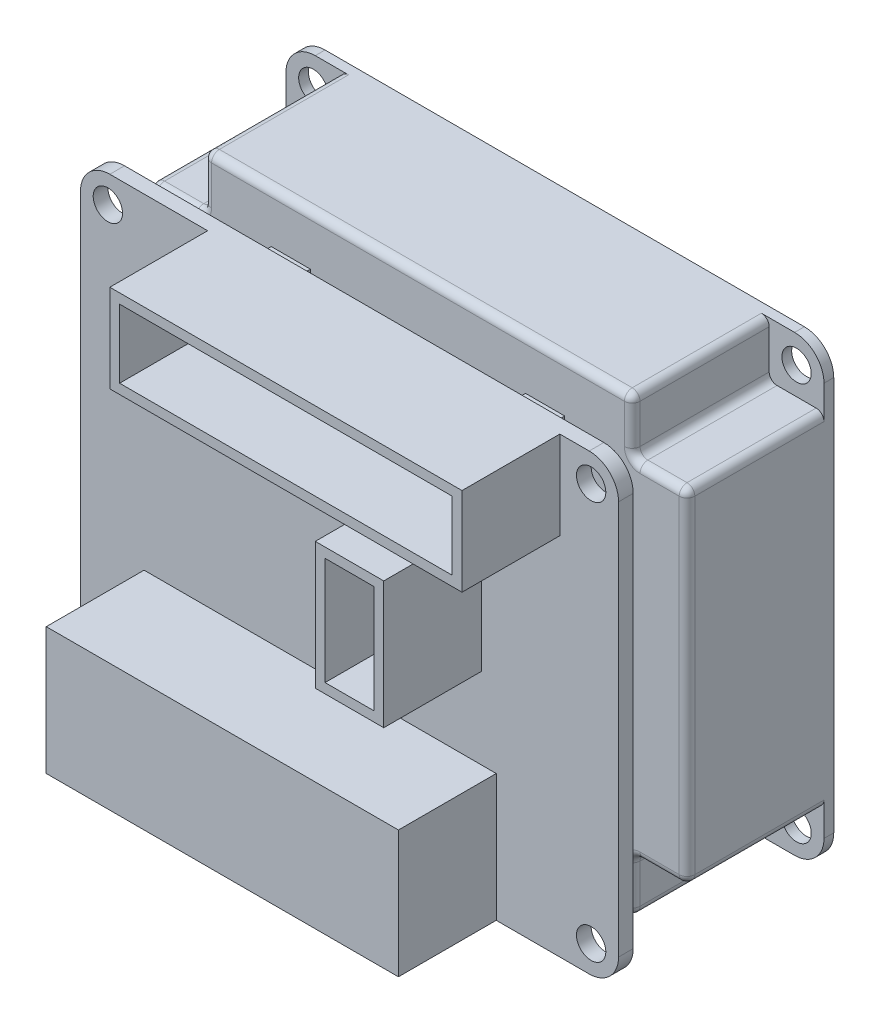
from build123d import *

# Parameters (mm, degrees)
SKETCH_1_W               = 55
SKETCH_1_H               = 46.3
EXTRUDE_1_DEPTH          = 15
SKETCH_2_W               = 5.6
SKETCH_2_H               = 5.6
CUT_EXTRUDE_1_DEPTH      = 14
SKETCH_3_R               = 1.5
CUT_EXTRUDE_2_DEPTH      = 1
MIRROR_2_COPY_1_SKETCH_W = 5.6
MIRROR_2_COPY_1_SKETCH_H = 5.6
MIRROR_2_COPY_1_DEPTH    = 14
MIRROR_2_COPY_2_SKETCH_R = 1.5
MIRROR_2_COPY_2_DEPTH    = 1
FILLET_1_R               = 3
FILLET_2_R               = 0.8
SKETCH_5_W               = 4
SKETCH_5_H               = 36
EXTRUDE_2_DEPTH          = 5.5
SKETCH_6_R               = 1.5
EXTRUDE_3_DEPTH          = 1.5
SKETCH_7_W               = 36
SKETCH_7_H               = 9
SKETCH_7_W_2             = 34
SKETCH_7_H_2             = 7
SKETCH_7_W_3             = 7
SKETCH_7_H_3             = 13
SKETCH_7_W_4             = 5
SKETCH_7_H_4             = 11
EXTRUDE_4_DEPTH          = 10
SKETCH_9_W               = 34
SKETCH_9_H               = 8
CUT_EXTRUDE_3_DEPTH      = 11


with BuildPart() as part:
    # 草图1 → 凸台-拉伸1 (new body)
    with BuildSketch(Plane.XY):
        Rectangle(SKETCH_1_W, SKETCH_1_H)
    extrude(amount=EXTRUDE_1_DEPTH)

    # 草图2 → 切除-拉伸1 (cut)
    with BuildSketch(Plane.XY.offset(15)):
        with Locations((-24.7, 20.35)):
            Rectangle(SKETCH_2_W, SKETCH_2_H)
    cut_extrude_1 = extrude(amount=-CUT_EXTRUDE_1_DEPTH, mode=Mode.SUBTRACT)

    # 草图3 → 切除-拉伸2 (cut)
    with BuildSketch(Plane.XY.offset(1)):
        with Locations((-24.7, 20.35)):
            Circle(SKETCH_3_R)
    cut_extrude_2 = extrude(amount=-CUT_EXTRUDE_2_DEPTH, mode=Mode.SUBTRACT)

    # 镜向1: 切除-拉伸1, 切除-拉伸2 across plane
    add(cut_extrude_1.mirror(Plane.ZX), mode=Mode.SUBTRACT)
    add(cut_extrude_2.mirror(Plane.ZX), mode=Mode.SUBTRACT)

    # 镜向2: 切除-拉伸1, 切除-拉伸2 across plane
    add(cut_extrude_1.mirror(Plane(origin=(0, 0, 0), x_dir=(0, 0, 1), z_dir=(1, 0, 0))), mode=Mode.SUBTRACT)
    add(cut_extrude_2.mirror(Plane(origin=(0, 0, 0), x_dir=(0, 0, 1), z_dir=(1, 0, 0))), mode=Mode.SUBTRACT)

    # 镜向2 copy 1 sketch → 镜向2 copy 1 (cut)
    with BuildSketch(Plane(origin=(0, 0, 15), x_dir=(-1, 0, 0), z_dir=(0, 0, 1))):
        with Locations((-24.7, 20.35)):
            Rectangle(MIRROR_2_COPY_1_SKETCH_W, MIRROR_2_COPY_1_SKETCH_H)
    extrude(amount=-MIRROR_2_COPY_1_DEPTH, mode=Mode.SUBTRACT)

    # 镜向2 copy 2 sketch → 镜向2 copy 2 (cut)
    with BuildSketch(Plane(origin=(0, 0, 1), x_dir=(-1, 0, 0), z_dir=(0, 0, 1))):
        with Locations((-24.7, 20.35)):
            Circle(MIRROR_2_COPY_2_SKETCH_R)
    extrude(amount=-MIRROR_2_COPY_2_DEPTH, mode=Mode.SUBTRACT)

    # 圆角1
    fillet_1_edges = [part.edges().sort_by_distance(p)[0] for p in [
        (-27.5, 23.15, 0.5),
        (-27.5, -23.15, 0.5),
        (27.5, -23.15, 0.5),
        (27.5, 23.15, 0.5),
    ]]
    fillet(fillet_1_edges, radius=FILLET_1_R)

    # 圆角2
    fillet_2_edges = [part.edges().sort_by_distance(p)[0] for p in [
        (-27.5, 0, 15),
        (-27.5, 17.55, 8),
        (-21.9, 23.15, 8),
        (-21.9, 17.55, 8),
        (-24.7, 17.55, 15),
        (-21.9, 20.35, 15),
        (0, -23.15, 15),
        (-24.7, -17.55, 15),
        (-27.5, -17.55, 8),
        (-21.9, -20.35, 15),
        (-21.9, -17.55, 8),
        (-21.9, -23.15, 8),
        (27.5, 0, 15),
        (27.5, -17.55, 8),
        (21.9, -23.15, 8),
        (21.9, -17.55, 8),
        (24.7, -17.55, 15),
        (21.9, -20.35, 15),
        (0, 23.15, 15),
        (24.7, 17.55, 15),
        (27.5, 17.55, 8),
        (21.9, 20.35, 15),
        (21.9, 17.55, 8),
        (21.9, 23.15, 8),
    ]]
    fillet(fillet_2_edges, radius=FILLET_2_R)

    # 草图5 → 凸台-拉伸2 (add)
    with BuildSketch(Plane.XY.offset(15)):
        with Locations((-13, 0)):
            Rectangle(SKETCH_5_W, SKETCH_5_H)
        with Locations((13, 0)):
            Rectangle(SKETCH_5_W, SKETCH_5_H)
    extrude(amount=EXTRUDE_2_DEPTH)

    # 草图6 → 凸台-拉伸3 (add)
    with BuildSketch(Plane.XY.offset(20.5)):
        with BuildLine():
            Line((24.5, 23.15), (-24.5, 23.15))
            ThreePointArc((-24.5, 23.15), (-26.621320344, 22.271320344), (-27.5, 20.15))
            Line((-27.5, 20.15), (-27.5, -20.15))
            ThreePointArc((-27.5, -20.15), (-26.621320344, -22.271320344), (-24.5, -23.15))
            Line((-24.5, -23.15), (24.5, -23.15))
            ThreePointArc((24.5, -23.15), (26.621320344, -22.271320344), (27.5, -20.15))
            Line((27.5, -20.15), (27.5, 20.15))
            ThreePointArc((27.5, 20.15), (26.621320344, 22.271320344), (24.5, 23.15))
        make_face()
        with Locations((-24.7, 20.35)):
            Circle(SKETCH_6_R, mode=Mode.SUBTRACT)
        with Locations((24.7, 20.35)):
            Circle(SKETCH_6_R, mode=Mode.SUBTRACT)
        with Locations((-24.7, -20.35)):
            Circle(SKETCH_6_R, mode=Mode.SUBTRACT)
        with Locations((24.7, -20.35)):
            Circle(SKETCH_6_R, mode=Mode.SUBTRACT)
    extrude(amount=EXTRUDE_3_DEPTH)

    # 草图7 → 凸台-拉伸4 (add)
    with BuildSketch(Plane.XY.offset(22)):
        with Locations((3.5, 18.65)):
            Rectangle(SKETCH_7_W, SKETCH_7_H)
        with Locations((3.5, 18.65)):
            Rectangle(SKETCH_7_W_2, SKETCH_7_H_2, mode=Mode.SUBTRACT)
        with Locations((10, 4.65)):
            Rectangle(SKETCH_7_W_3, SKETCH_7_H_3)
        with Locations((10, 4.65)):
            Rectangle(SKETCH_7_W_4, SKETCH_7_H_4, mode=Mode.SUBTRACT)
        with Locations((-3, -16.65)):
            Rectangle(SKETCH_7_W, SKETCH_7_H_3)
    extrude(amount=EXTRUDE_4_DEPTH)

    # 草图9 → 切除-拉伸3 (cut)
    with BuildSketch(Plane.XZ.offset(23.15)):
        with Locations((-3, 27)):
            Rectangle(SKETCH_9_W, SKETCH_9_H)
    extrude(amount=-CUT_EXTRUDE_3_DEPTH, mode=Mode.SUBTRACT)


solid = part.part
